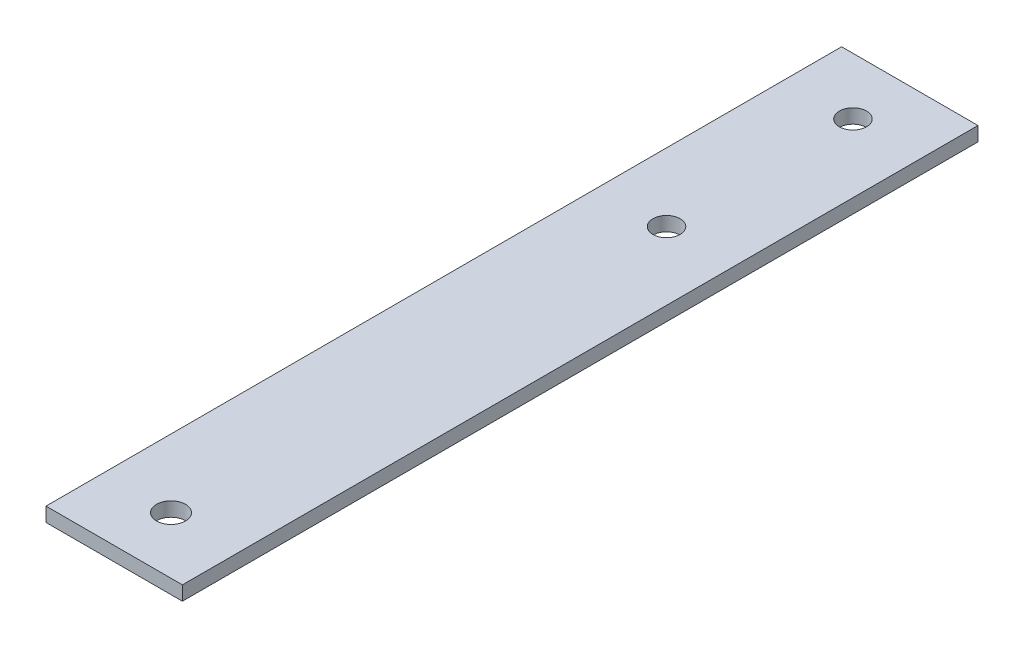
from build123d import *

# Parameters (mm, degrees)
SKETCH1_W           = 30.48
SKETCH1_H           = 177.8
SKETCH1_R           = 3.048
SKETCH1_R_2         = 3.2385
BOSS_EXTRUDE1_DEPTH = 3.175


with BuildPart() as part:
    # Sketch1 → Boss-Extrude1 (new body)
    with BuildSketch(Plane(origin=(0, 0, 0), x_dir=(1, 0, 0), z_dir=(0, 1, 0))):
        with Locations((-35.963933877, 0)):
            Rectangle(SKETCH1_W, SKETCH1_H)
        with Locations((-35.963933877, 76.2)):
            Circle(SKETCH1_R, mode=Mode.SUBTRACT)
        with Locations((-35.963933877, 34.529268)):
            Circle(SKETCH1_R, mode=Mode.SUBTRACT)
        with Locations((-35.963933877, -76.2)):
            Circle(SKETCH1_R_2, mode=Mode.SUBTRACT)
    extrude(amount=BOSS_EXTRUDE1_DEPTH)


solid = part.part
